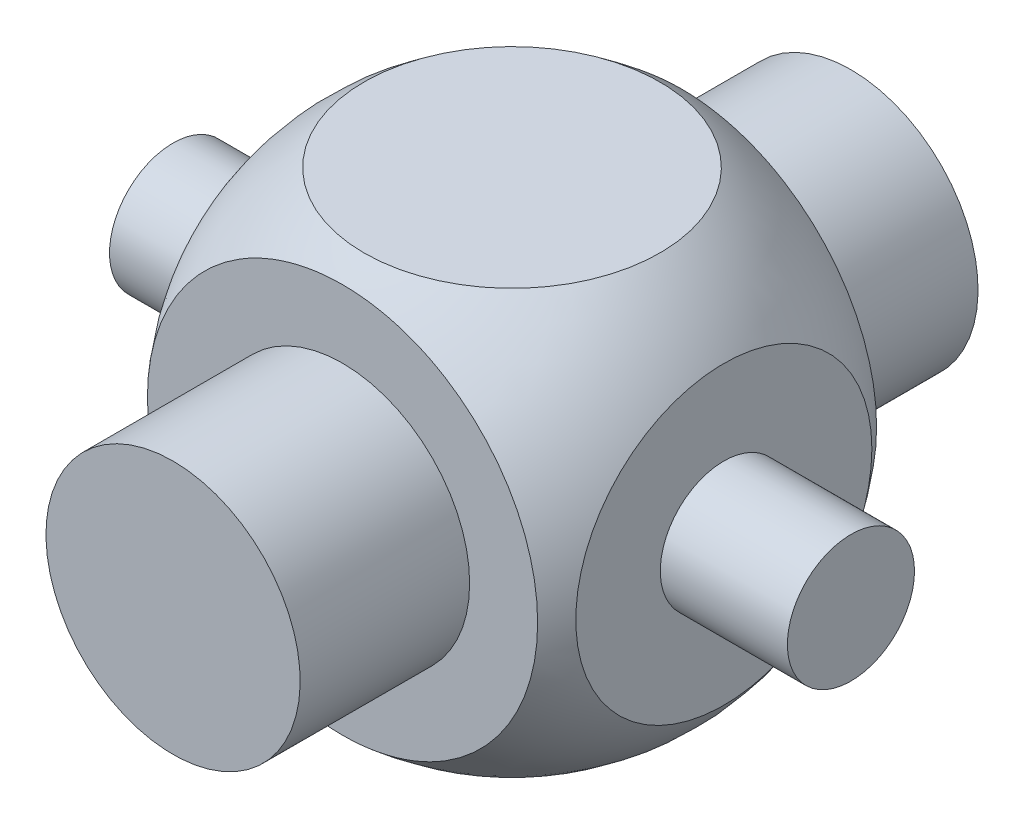
from build123d import *

# Parameters (mm, degrees)
CUT_EXTRUDE1_DEPTH      = 8.470943715
CUT_EXTRUDE1_DEPTH_BACK = 8.470943715
SKETCH3_OUTSIDE_W       = 10.214
SKETCH3_OUTSIDE_H       = 10.214
SKETCH3_OUTSIDE_W_2     = 4
SKETCH3_OUTSIDE_H_2     = 5
CUT_EXTRUDE2_DEPTH      = 7.641159537
CUT_EXTRUDE2_DEPTH_BACK = 7.641159537
SKETCH4_OUTSIDE_W       = 9.868
SKETCH4_OUTSIDE_H       = 8.768
SKETCH4_OUTSIDE_W_2     = 5
SKETCH4_OUTSIDE_H_2     = 5
SKETCH5_R               = 0.75
BOSS_EXTRUDE1_DEPTH     = 1.5
SKETCH6_R               = 1.5
BOSS_EXTRUDE2_DEPTH     = 2


with BuildPart() as part:
    # Sketch2 → Revolve3 (revolve)
    with BuildSketch(Plane(origin=(0, 0, 0), x_dir=(0, 0, -1), z_dir=(1, 0, 0))):
        with BuildLine():
            Line((0, 0), (0, 6.1))
            ThreePointArc((0, 6.1), (3.05, 3.05), (0, 0))
        make_face()
    revolve(axis=Axis((0, 0, 0), (0, 1, 0)))

    # Sketch3 outside → Cut-Extrude1 (cut, two sides: drawn at the far end of the back side and taken through both)
    with BuildSketch(Plane(origin=(0, 0, 0), x_dir=(0, 0, -1), z_dir=(1, 0, 0)).offset(-CUT_EXTRUDE1_DEPTH_BACK)):
        with Locations((0, 3.05)):
            Rectangle(SKETCH3_OUTSIDE_W, SKETCH3_OUTSIDE_H)
        with Locations((0, 3.05)):
            Rectangle(SKETCH3_OUTSIDE_W_2, SKETCH3_OUTSIDE_H_2, mode=Mode.SUBTRACT)
    extrude(amount=CUT_EXTRUDE1_DEPTH + CUT_EXTRUDE1_DEPTH_BACK, mode=Mode.SUBTRACT)

    # Sketch4 outside → Cut-Extrude2 (cut, two sides: drawn at the far end of the back side and taken through both)
    with BuildSketch(Plane.XY.offset(-CUT_EXTRUDE2_DEPTH_BACK)):
        with Locations((0, 3.05)):
            Rectangle(SKETCH4_OUTSIDE_W, SKETCH4_OUTSIDE_H)
        with Locations((0, 3.05)):
            Rectangle(SKETCH4_OUTSIDE_W_2, SKETCH4_OUTSIDE_H_2, mode=Mode.SUBTRACT)
    extrude(amount=CUT_EXTRUDE2_DEPTH + CUT_EXTRUDE2_DEPTH_BACK, mode=Mode.SUBTRACT)

    # Sketch5 → Boss-Extrude1 (add)
    with BuildSketch(Plane(origin=(2.5, 0, 0), x_dir=(0, 0, -1), z_dir=(1, 0, 0))):
        with Locations((0, 3.05)):
            Circle(SKETCH5_R)
    boss_extrude1 = extrude(amount=BOSS_EXTRUDE1_DEPTH)

    # Mirror1: Boss-Extrude1 across plane
    add(boss_extrude1.mirror(Plane(origin=(0, 0, 0), x_dir=(0, 0, 1), z_dir=(1, 0, 0))))

    # Sketch6 → Boss-Extrude2 (add)
    with BuildSketch(Plane(origin=(0, 0, -2), x_dir=(-1, 0, 0), z_dir=(0, 0, -1))):
        with Locations(Location((0, 3.05, 0), (0, 0, 90))):
            Circle(SKETCH6_R)
    boss_extrude2 = extrude(amount=BOSS_EXTRUDE2_DEPTH)

    # Mirror2: Boss-Extrude2 across plane
    add(boss_extrude2.mirror(Plane.XY))


solid = part.part
